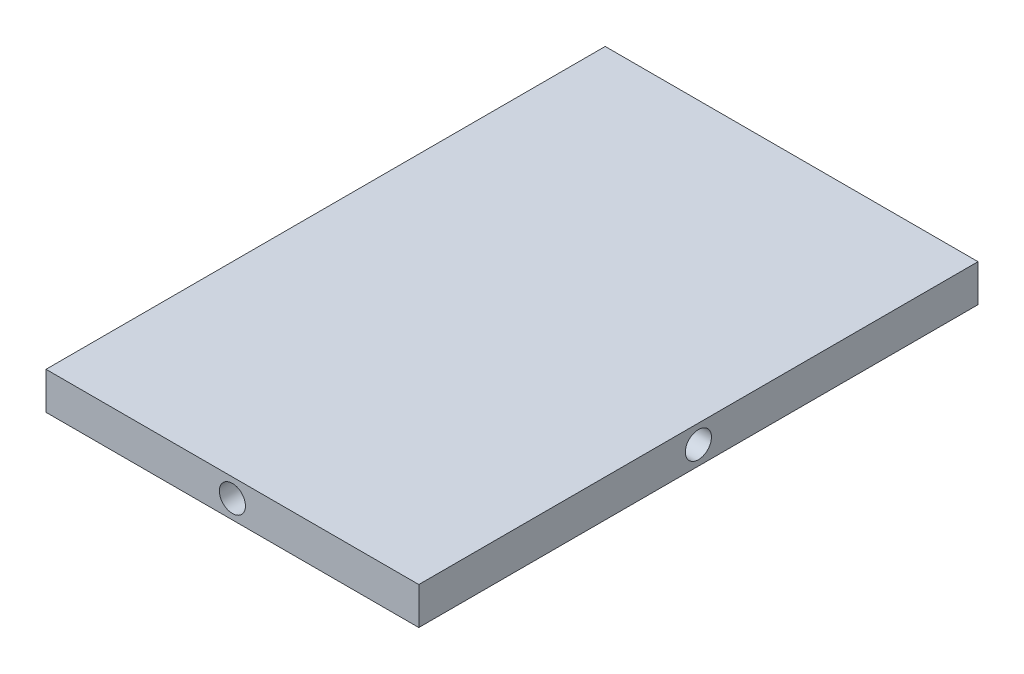
from build123d import *

# Parameters (mm, degrees)
SKETCH_1_W          = 100
SKETCH_1_H          = 150
EXTRUDE_1_DEPTH     = 10
SKETCH_2_R          = 3.5
CUT_EXTRUDE_1_DEPTH = 10
SKETCH_3_R          = 3.5
CUT_EXTRUDE_2_DEPTH = 10
CUT_EXTRUDE_3_DEPTH = 10
SKETCH_5_R          = 3.5
CUT_EXTRUDE_4_DEPTH = 10


with BuildPart() as part:
    # 草图1 → 凸台-拉伸1 (new body)
    with BuildSketch(Plane(origin=(0, 0, 0), x_dir=(1, 0, 0), z_dir=(0, 1, 0))):
        Rectangle(SKETCH_1_W, SKETCH_1_H)
    extrude(amount=EXTRUDE_1_DEPTH)

    # 草图2 → 切除-拉伸1 (cut)
    with BuildSketch(Plane.XY.offset(75)):
        with Locations((0, 5)):
            Circle(SKETCH_2_R)
    extrude(amount=-CUT_EXTRUDE_1_DEPTH, mode=Mode.SUBTRACT)

    # 草图3 → 切除-拉伸2 (cut)
    with BuildSketch(Plane(origin=(50, 0, 0), x_dir=(0, 0, -1), z_dir=(1, 0, 0))):
        with Locations((0, 5)):
            Circle(SKETCH_3_R)
    extrude(amount=-CUT_EXTRUDE_2_DEPTH, mode=Mode.SUBTRACT)

    # 草图4 → 切除-拉伸3 (cut)
    with BuildSketch(Plane(origin=(0, 0, -75), x_dir=(-1, 0, 0), z_dir=(0, 0, -1))):
        with BuildLine():
            ThreePointArc((3.482630166, 5.348263017), (0, 8.5), (-3.482630166, 5.348263017))
            Line((-3.482630166, 5.348263017), (0, 5))
            Line((0, 5), (3.482630166, 5.348263017))
        make_face()
        with BuildLine():
            Line((0, 5), (-3.482630166, 5.348263017))
            ThreePointArc((-3.482630166, 5.348263017), (-3.5, 5), (-3.482630166, 4.651736983))
            Line((-3.482630166, 4.651736983), (0, 5))
        make_face()
        with BuildLine():
            Line((3.482630166, 5.348263017), (0, 5))
            Line((0, 5), (3.482630166, 4.651736983))
            ThreePointArc((3.482630166, 4.651736983), (3.495654844, 4.825652043), (3.5, 5))
            ThreePointArc((3.5, 5), (3.495654844, 5.174347957), (3.482630166, 5.348263017))
        make_face()
        with BuildLine():
            Line((3.482630166, 4.651736983), (0, 5))
            Line((0, 5), (-3.482630166, 4.651736983))
            ThreePointArc((-3.482630166, 4.651736983), (0, 1.5), (3.482630166, 4.651736983))
        make_face()
    extrude(amount=-CUT_EXTRUDE_3_DEPTH, mode=Mode.SUBTRACT)

    # 草图5 → 切除-拉伸4 (cut)
    with BuildSketch(Plane.ZY.offset(50)):
        with Locations((0, 5)):
            Circle(SKETCH_5_R)
    extrude(amount=-CUT_EXTRUDE_4_DEPTH, mode=Mode.SUBTRACT)


solid = part.part
